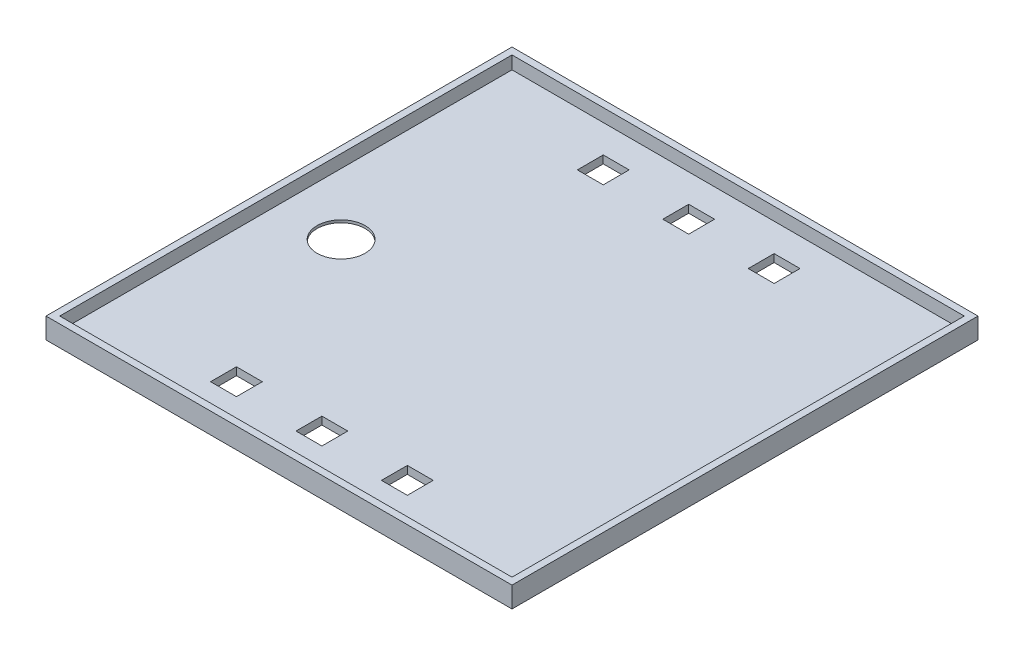
from build123d import *

# Parameters (mm, degrees)
SKETCH1_W           = 90
SKETCH1_H           = 90
BOSS_EXTRUDE1_DEPTH = 4
SKETCH2_W           = 87.35
SKETCH2_H           = 87.35
CUT_EXTRUDE2_DEPTH  = 2.5
SKETCH6_W           = 5
SKETCH6_H           = 5
CUT_EXTRUDE5_DEPTH  = 3
SKETCH7_R           = 6.5
CUT_EXTRUDE6_DEPTH  = 1
SKETCH8_R           = 4.637905468
CUT_EXTRUDE7_DEPTH  = 2.7


with BuildPart() as part:
    # Sketch1 → Boss-Extrude1 (new body)
    with BuildSketch(Plane(origin=(0, 0, 0), x_dir=(1, 0, 0), z_dir=(0, 1, 0))):
        Rectangle(SKETCH1_W, SKETCH1_H)
    extrude(amount=BOSS_EXTRUDE1_DEPTH)

    # Sketch2 → Cut-Extrude2 (cut)
    with BuildSketch(Plane(origin=(0, 4, 0), x_dir=(1, 0, 0), z_dir=(0, 1, 0))):
        Rectangle(SKETCH2_W, SKETCH2_H)
    extrude(amount=-CUT_EXTRUDE2_DEPTH, mode=Mode.SUBTRACT)

    # Sketch6 → Cut-Extrude5 (cut)
    with BuildSketch(Plane.XZ):
        with Locations((14.866822719, -35.757474477)):
            Rectangle(SKETCH6_W, SKETCH6_H)
        with Locations((-1.633815548, -35.757474477)):
            Rectangle(SKETCH6_W, SKETCH6_H)
        with Locations((-18.134453815, -35.757474477)):
            Rectangle(SKETCH6_W, SKETCH6_H)
        with Locations((14.87666148, 35.092600442)):
            Rectangle(SKETCH6_W, SKETCH6_H)
        with Locations((-1.623976787, 35.092600442)):
            Rectangle(SKETCH6_W, SKETCH6_H)
        with Locations((-18.124615054, 35.092600442)):
            Rectangle(SKETCH6_W, SKETCH6_H)
    extrude(amount=-CUT_EXTRUDE5_DEPTH, mode=Mode.SUBTRACT)

    # Sketch7 → Cut-Extrude6 (cut)
    with BuildSketch(Plane.XZ):
        with Locations((-31.818415868, 1.190037438)):
            Circle(SKETCH7_R)
    extrude(amount=-CUT_EXTRUDE6_DEPTH, mode=Mode.SUBTRACT)

    # Sketch8 → Cut-Extrude7 (cut)
    with BuildSketch(Plane.XZ.offset(-1)):
        with Locations((-31.818415868, 1.190037438)):
            Circle(SKETCH8_R)
    extrude(amount=-CUT_EXTRUDE7_DEPTH, mode=Mode.SUBTRACT)


solid = part.part
